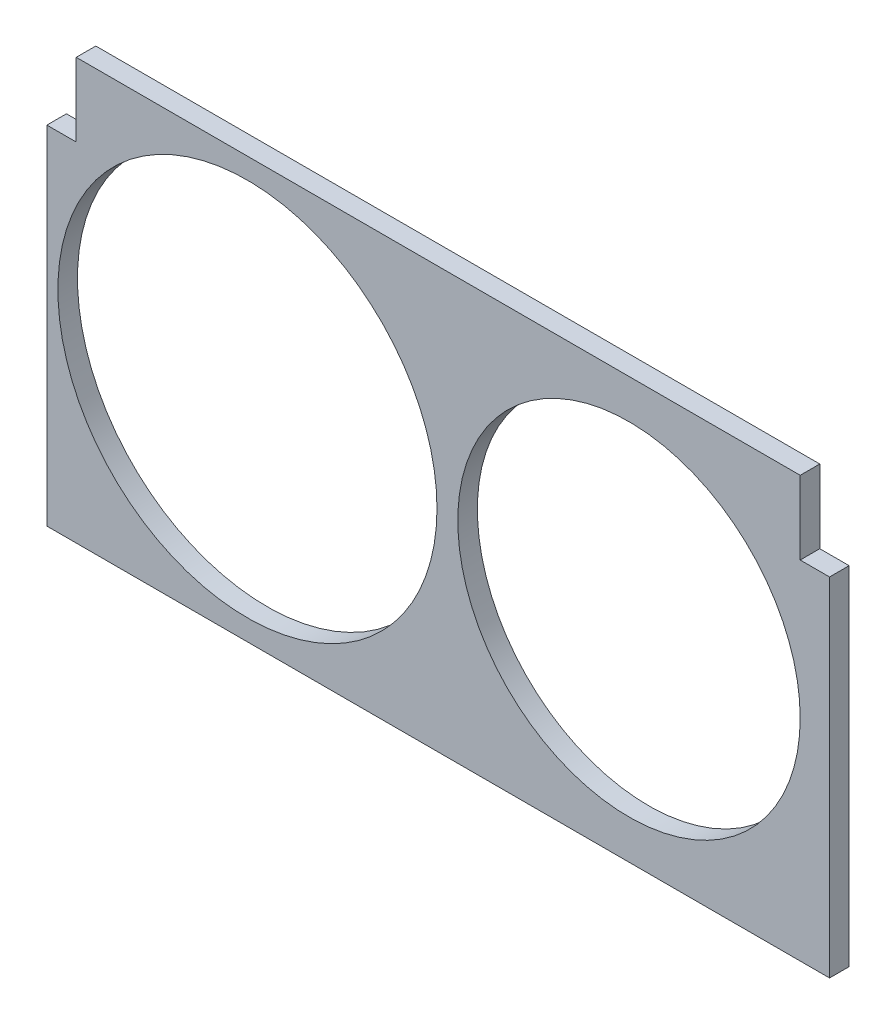
from build123d import *

# Parameters (mm, degrees)
SKETCH1_R           = 77.5
SKETCH1_R_2         = 70
BOSS_EXTRUDE1_DEPTH = 8
SKETCH2_R           = 1.5
CUT_EXTRUDE1_DEPTH  = 6


with BuildPart() as part:
    # Sketch1 → Boss-Extrude1 (new body)
    with BuildSketch(Plane.XY):
        Polygon((-148.270283039, 111.64556962), (147.729716961, 111.64556962), (147.729716961, 81.64556962), (159.729716961, 81.64556962), (159.729716961, -60.35443038), (-160.270283039, -60.35443038), (-160.270283039, 81.64556962), (-148.270283039, 81.64556962), align=None)
        with Locations((-78.270283039, 25.64556962)):
            Circle(SKETCH1_R, mode=Mode.SUBTRACT)
        with Locations((77.729716961, 25.64556962)):
            Circle(SKETCH1_R_2, mode=Mode.SUBTRACT)
    extrude(amount=BOSS_EXTRUDE1_DEPTH)

    # Sketch2 → Cut-Extrude1 (cut)
    with BuildSketch(Plane.XY):
        with Locations((-0.270283039, 96.64556962)):
            Circle(SKETCH2_R)
        with Locations((144.729716961, -45.35443038)):
            Circle(SKETCH2_R)
        with Locations((-145.270283039, -45.35443038)):
            Circle(SKETCH2_R)
    extrude(amount=CUT_EXTRUDE1_DEPTH, mode=Mode.SUBTRACT)


solid = part.part
